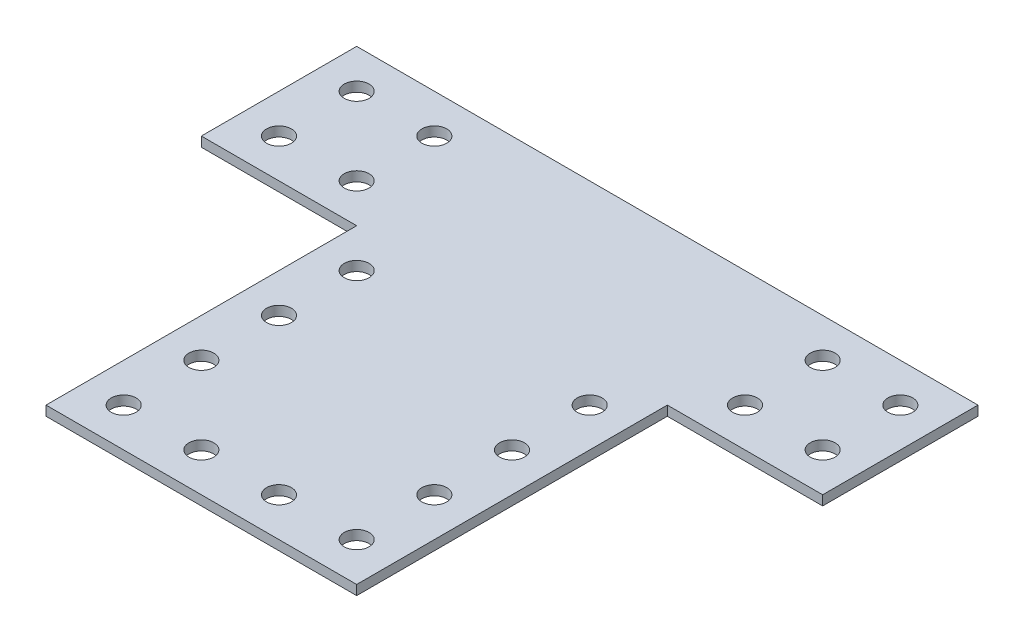
from build123d import *

# Parameters (mm, degrees)
BOSS_EXTRUDE1_DEPTH = 1.5875
SKETCH4_R           = 2.032
CUT_EXTRUDE1_DEPTH  = 1.5875


with BuildPart() as part:
    # Sketch3 → Boss-Extrude1 (new body)
    with BuildSketch(Plane(origin=(0, 0, 0), x_dir=(1, 0, 0), z_dir=(0, 1, 0))):
        Polygon((0, 0), (101.6, 0), (101.6, -25.4), (76.2, -25.4), (76.2, -76.2), (25.4, -76.2), (25.4, -25.4), (0, -25.4), align=None)
    extrude(amount=BOSS_EXTRUDE1_DEPTH)

    # Sketch4 → Cut-Extrude1 (cut)
    with BuildSketch(Plane(origin=(0, 1.5875, 0), x_dir=(1, 0, 0), z_dir=(0, 1, 0))):
        with Locations((6.35, -6.35)):
            Circle(SKETCH4_R)
        with Locations((19.05, -6.35)):
            Circle(SKETCH4_R)
        with Locations((82.55, -6.35)):
            Circle(SKETCH4_R)
        with Locations((95.25, -6.35)):
            Circle(SKETCH4_R)
        with Locations((107.95, -6.35)):
            Circle(SKETCH4_R)
        with Locations((120.65, -6.35)):
            Circle(SKETCH4_R)
        with Locations((133.35, -6.35)):
            Circle(SKETCH4_R)
        with Locations((146.05, -6.35)):
            Circle(SKETCH4_R)
        with Locations((19.05, -19.05)):
            Circle(SKETCH4_R)
        with Locations((82.55, -19.05)):
            Circle(SKETCH4_R)
        with Locations((95.25, -19.05)):
            Circle(SKETCH4_R)
        with Locations((107.95, -19.05)):
            Circle(SKETCH4_R)
        with Locations((120.65, -19.05)):
            Circle(SKETCH4_R)
        with Locations((133.35, -19.05)):
            Circle(SKETCH4_R)
        with Locations((146.05, -19.05)):
            Circle(SKETCH4_R)
        with Locations((19.05, -31.75)):
            Circle(SKETCH4_R)
        with Locations((31.75, -31.75)):
            Circle(SKETCH4_R)
        with Locations((69.85, -31.75)):
            Circle(SKETCH4_R)
        with Locations((82.55, -31.75)):
            Circle(SKETCH4_R)
        with Locations((95.25, -31.75)):
            Circle(SKETCH4_R)
        with Locations((107.95, -31.75)):
            Circle(SKETCH4_R)
        with Locations((120.65, -31.75)):
            Circle(SKETCH4_R)
        with Locations((133.35, -31.75)):
            Circle(SKETCH4_R)
        with Locations((146.05, -31.75)):
            Circle(SKETCH4_R)
        with Locations((19.05, -44.45)):
            Circle(SKETCH4_R)
        with Locations((31.75, -44.45)):
            Circle(SKETCH4_R)
        with Locations((69.85, -44.45)):
            Circle(SKETCH4_R)
        with Locations((82.55, -44.45)):
            Circle(SKETCH4_R)
        with Locations((95.25, -44.45)):
            Circle(SKETCH4_R)
        with Locations((107.95, -44.45)):
            Circle(SKETCH4_R)
        with Locations((120.65, -44.45)):
            Circle(SKETCH4_R)
        with Locations((133.35, -44.45)):
            Circle(SKETCH4_R)
        with Locations((146.05, -44.45)):
            Circle(SKETCH4_R)
        with Locations((19.05, -57.15)):
            Circle(SKETCH4_R)
        with Locations((31.75, -57.15)):
            Circle(SKETCH4_R)
        with Locations((69.85, -57.15)):
            Circle(SKETCH4_R)
        with Locations((82.55, -57.15)):
            Circle(SKETCH4_R)
        with Locations((95.25, -57.15)):
            Circle(SKETCH4_R)
        with Locations((107.95, -57.15)):
            Circle(SKETCH4_R)
        with Locations((120.65, -57.15)):
            Circle(SKETCH4_R)
        with Locations((133.35, -57.15)):
            Circle(SKETCH4_R)
        with Locations((146.05, -57.15)):
            Circle(SKETCH4_R)
        with Locations((19.05, -69.85)):
            Circle(SKETCH4_R)
        with Locations((31.75, -69.85)):
            Circle(SKETCH4_R)
        with Locations((44.45, -69.85)):
            Circle(SKETCH4_R)
        with Locations((57.15, -69.85)):
            Circle(SKETCH4_R)
        with Locations((69.85, -69.85)):
            Circle(SKETCH4_R)
        with Locations((82.55, -69.85)):
            Circle(SKETCH4_R)
        with Locations((95.25, -69.85)):
            Circle(SKETCH4_R)
        with Locations((107.95, -69.85)):
            Circle(SKETCH4_R)
        with Locations((120.65, -69.85)):
            Circle(SKETCH4_R)
        with Locations((133.35, -69.85)):
            Circle(SKETCH4_R)
        with Locations((146.05, -69.85)):
            Circle(SKETCH4_R)
        with Locations((6.35, -19.05)):
            Circle(SKETCH4_R)
        with Locations((6.35, -31.75)):
            Circle(SKETCH4_R)
        with Locations((6.35, -44.45)):
            Circle(SKETCH4_R)
        with Locations((6.35, -57.15)):
            Circle(SKETCH4_R)
        with Locations((6.35, -69.85)):
            Circle(SKETCH4_R)
    extrude(amount=-CUT_EXTRUDE1_DEPTH, mode=Mode.SUBTRACT)


solid = part.part
